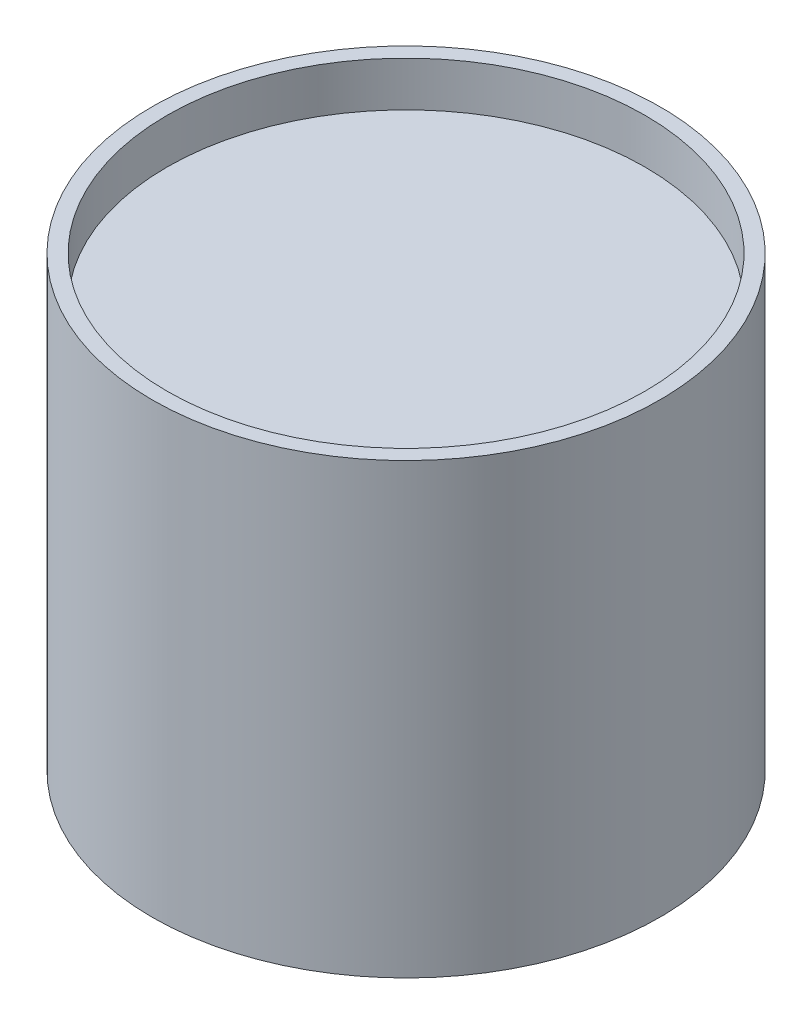
from build123d import *

# Parameters (mm, degrees)
SKETCH1_R           = 17
BOSS_EXTRUDE1_DEPTH = 30
SKETCH2_R           = 16
CUT_EXTRUDE1_DEPTH  = 3
SKETCH3_R           = 1
CUT_EXTRUDE2_DEPTH  = 2
FILLET1_R           = 1


with BuildPart() as part:
    # Sketch1 → Boss-Extrude1 (new body)
    with BuildSketch(Plane(origin=(0, 0, 0), x_dir=(1, 0, 0), z_dir=(0, 1, 0))):
        Circle(SKETCH1_R)
    extrude(amount=BOSS_EXTRUDE1_DEPTH)

    # Sketch2 → Cut-Extrude1 (cut)
    with BuildSketch(Plane(origin=(0, 30, 0), x_dir=(1, 0, 0), z_dir=(0, 1, 0))):
        Circle(SKETCH2_R)
    extrude(amount=-CUT_EXTRUDE1_DEPTH, mode=Mode.SUBTRACT)

    # Sketch3 → Cut-Extrude2 (cut)
    with BuildSketch(Plane.XZ):
        Circle(SKETCH3_R)
    extrude(amount=-CUT_EXTRUDE2_DEPTH, mode=Mode.SUBTRACT)

    # Fillet1
    fillet1_edges = [part.edges().sort_by_distance(p)[0] for p in [
        (-1, 2, 0),
    ]]
    fillet(fillet1_edges, radius=FILLET1_R)


solid = part.part
